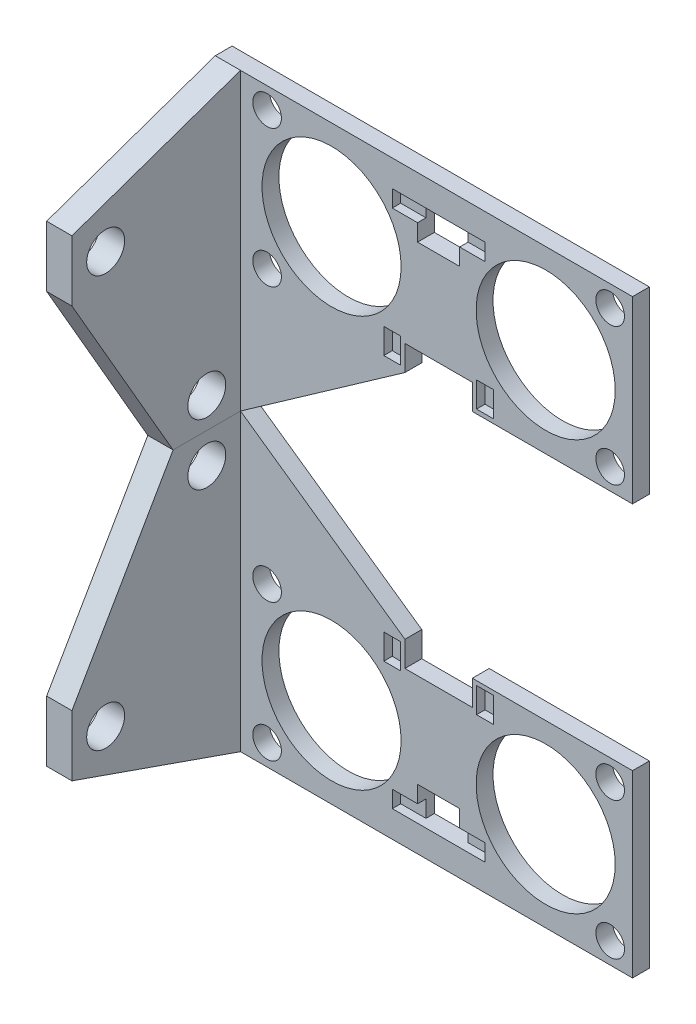
from build123d import *

# Parameters (mm, degrees)
SKETCH_1_W          = 46
SKETCH_1_H          = 21.3
EXTRUDE_1_DEPTH     = 2
SKETCH_2_R          = 8.25
CUT_EXTRUDE_1_DEPTH = 3
SKETCH_3_W          = 8
SKETCH_3_H          = 3
CUT_EXTRUDE_2_DEPTH = 3
SKETCH_4_W          = 5
SKETCH_4_H          = 4
CUT_EXTRUDE_3_DEPTH = 3
SKETCH_5_W          = 3
SKETCH_5_H          = 2
SKETCH_5_W_2        = 2
SKETCH_5_H_2        = 3
CUT_EXTRUDE_4_DEPTH = 1
HOLE_WIZARD_M3_1_D  = 3.4
SKETCH_11_W         = 2
SKETCH_11_H         = 21.3
EXTRUDE_4_DEPTH     = 0.5
SKETCH_12_W         = 3
SKETCH_12_H         = 35
EXTRUDE_5_DEPTH     = 2
SKETCH_17_W         = 3
SKETCH_17_H         = 28
EXTRUDE_8_DEPTH     = 20
HOLE_WIZARD_M4_2_D  = 4.5
EXTRUDE_9_DEPTH     = 3
CHAMFER_1_SIZE      = 12
CHAMFER_1_SIZE2     = 20.784609691
EXTRUDE_10_DEPTH    = 2


with BuildPart() as part:
    # 草圖1 → 填料-伸長1 (new body)
    with BuildSketch(Plane.XY):
        Rectangle(SKETCH_1_W, SKETCH_1_H)
    extrude(amount=EXTRUDE_1_DEPTH)

    # 草圖2 → 除料-伸長1 (cut, through all)
    with BuildSketch(Plane.XY.offset(2)):
        with Locations((-12.7, 0)):
            Circle(SKETCH_2_R)
        with Locations((12.7, 0)):
            Circle(SKETCH_2_R)
    extrude(amount=-CUT_EXTRUDE_1_DEPTH, mode=Mode.SUBTRACT)

    # 草圖3 → 除料-伸長2 (cut, through all)
    with BuildSketch(Plane.XY.offset(2)):
        with Locations((0, 9.15)):
            Rectangle(SKETCH_3_W, SKETCH_3_H)
    extrude(amount=-CUT_EXTRUDE_2_DEPTH, mode=Mode.SUBTRACT)

    # 草圖4 → 除料-伸長3 (cut, through all)
    with BuildSketch(Plane.XY.offset(2)):
        with Locations((0, -5.5)):
            Rectangle(SKETCH_4_W, SKETCH_4_H)
    extrude(amount=-CUT_EXTRUDE_3_DEPTH, mode=Mode.SUBTRACT)

    # 草圖5 → 除料-伸長4 (cut)
    with BuildSketch(Plane.XY.offset(2)):
        with Locations((4, -6.5)):
            Rectangle(SKETCH_5_W, SKETCH_5_H)
        with Locations((-5.5, 8.65)):
            Rectangle(SKETCH_5_W_2, SKETCH_5_H_2)
        with Locations((5.5, 8.65)):
            Rectangle(SKETCH_5_W_2, SKETCH_5_H_2)
        with Locations((-4, -6.5)):
            Rectangle(SKETCH_5_W, SKETCH_5_H)
    extrude(amount=-CUT_EXTRUDE_4_DEPTH, mode=Mode.SUBTRACT)

    # M3 餘隙孔1 (through all)
    with Locations(Plane.XY.offset(2)):
        with Locations((20.35, 8.15), (-20.35, -8.15), (-20.35, 8.15), (20.35, -8.15)):
            Hole(HOLE_WIZARD_M3_1_D / 2)

    # 草圖11 → 填料-伸長4 (add)
    with BuildSketch(Plane.ZY.offset(23)):
        with Locations((1, 0)):
            Rectangle(SKETCH_11_W, SKETCH_11_H)
    extrude(amount=EXTRUDE_4_DEPTH)

    # 草圖12 → 填料-伸長5 (add)
    with BuildSketch(Plane.XY):
        with Locations((-25, 6.85)):
            Rectangle(SKETCH_12_W, SKETCH_12_H)
    extrude(amount=EXTRUDE_5_DEPTH)

    # 草圖17 → 填料-伸長8 (add)
    with BuildSketch(Plane.XY.offset(2)):
        with Locations((-25, 10.35)):
            Rectangle(SKETCH_17_W, SKETCH_17_H)
    extrude(amount=EXTRUDE_8_DEPTH)

    # M4 餘隙孔2 (through all)
    with Locations(Plane.ZY.offset(26.5)):
        with Locations((6, 20.742304845), (18, -0.042304845)):
            Hole(HOLE_WIZARD_M4_2_D / 2)

    # 草圖22 → 填料-伸長9 (add)
    with BuildSketch(Plane.ZY.offset(26.5)):
        Polygon((22, -3.65), (2, -10.65), (2, -3.65), align=None)
    extrude(amount=-EXTRUDE_9_DEPTH)

    # 導角1
    chamfer_1_edges = [part.edges().sort_by_distance(p)[0] for p in [
        (-25, 24.35, 22),
    ]]
    chamfer_1_side = [part.faces().sort_by_distance(p)[0] for p in [
        (-25, 24.35, 11),
    ]]
    chamfer(chamfer_1_edges, length=CHAMFER_1_SIZE, length2=CHAMFER_1_SIZE2, reference=chamfer_1_side[0])

    # 草圖23 → 填料-伸長10 (add)
    with BuildSketch(Plane(origin=(0, 0, 0), x_dir=(-1, 0, 0), z_dir=(0, 0, -1))):
        Polygon((4, 10.65), (23.5, 24.35), (23.5, 10.65), align=None)
    extrude(amount=-EXTRUDE_10_DEPTH)


with BuildPart() as body_2:
    # 鏡射1: mirrored copy
    add(part.part.mirror(Plane.ZX.offset(24.35)))


solid = Compound([part.part, body_2.part])
